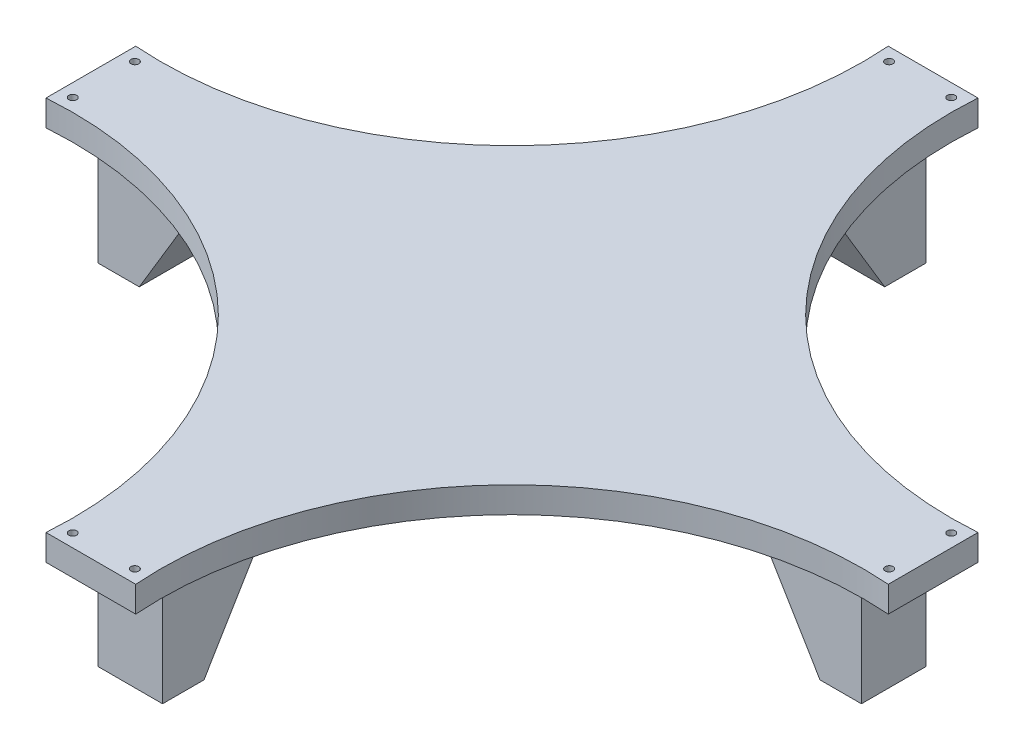
from build123d import *

# Parameters (mm, degrees)
SKETCH2_R           = 1.5
BOSS_EXTRUDE1_DEPTH = 10
SKETCH3_W           = 25
SKETCH3_H           = 40
SKETCH3_W_2         = 40
SKETCH3_H_2         = 25
BOSS_EXTRUDE2_DEPTH = 40
CUT_EXTRUDE1_DEPTH  = 40
CIRPATTERN1_COUNT   = 4


with BuildPart() as part:
    # Sketch2 → Boss-Extrude1 (new body)
    with BuildSketch(Plane(origin=(0, 0, 0), x_dir=(1, 0, 0), z_dir=(0, 1, 0))):
        with BuildLine():
            Line((162.66, -17.328961432), (162.66, 17.328961432))
            ThreePointArc((162.66, 17.328961432), (56.705609793, 56.705609793), (17.328961432, 162.66))
            Line((17.328961432, 162.66), (-17.328961432, 162.66))
            ThreePointArc((-17.328961432, 162.66), (-56.705609793, 56.705609793), (-162.66, 17.328961432))
            Line((-162.66, 17.328961432), (-162.66, -17.328961432))
            ThreePointArc((-162.66, -17.328961432), (-56.705609793, -56.705609793), (-17.328961432, -162.66))
            Line((-17.328961432, -162.66), (17.328961432, -162.66))
            ThreePointArc((17.328961432, -162.66), (56.705609793, -56.705609793), (162.66, -17.328961432))
        make_face()
        with Locations((-12, -157.66)):
            Circle(SKETCH2_R, mode=Mode.SUBTRACT)
        with Locations((-157.66, -12)):
            Circle(SKETCH2_R, mode=Mode.SUBTRACT)
        with Locations((12, -157.66)):
            Circle(SKETCH2_R, mode=Mode.SUBTRACT)
        with Locations((157.66, -12)):
            Circle(SKETCH2_R, mode=Mode.SUBTRACT)
        with Locations((-157.66, 12)):
            Circle(SKETCH2_R, mode=Mode.SUBTRACT)
        with Locations((-12, 157.66)):
            Circle(SKETCH2_R, mode=Mode.SUBTRACT)
        with Locations((157.66, 12)):
            Circle(SKETCH2_R, mode=Mode.SUBTRACT)
        with Locations((12, 157.66)):
            Circle(SKETCH2_R, mode=Mode.SUBTRACT)
    extrude(amount=BOSS_EXTRUDE1_DEPTH)

    # Sketch3 → Boss-Extrude2 (add)
    with BuildSketch(Plane.XZ):
        with Locations((0, 127.465698487)):
            Rectangle(SKETCH3_W, SKETCH3_H)
        with Locations((127.465698487, 0)):
            Rectangle(SKETCH3_W_2, SKETCH3_H_2)
        with Locations((0, -127.465698487)):
            Rectangle(SKETCH3_W, SKETCH3_H)
        with Locations((-127.465698487, 0)):
            Rectangle(SKETCH3_W_2, SKETCH3_H_2)
    extrude(amount=BOSS_EXTRUDE2_DEPTH)

    # Sketch4 → Cut-Extrude1 (cut)
    with BuildSketch(Plane(origin=(0, 0, -12.5), x_dir=(-1, 0, 0), z_dir=(0, 0, -1))):
        Polygon((-131.465698487, -40), (-107.465698487, 0), (-107.465698487, -40), align=None)
    cut_extrude1 = extrude(amount=-CUT_EXTRUDE1_DEPTH, mode=Mode.SUBTRACT)

    # CirPattern1: Cut-Extrude1 ×4 about axis
    cirpattern1_axis = Axis((0, 0, 0), (0, 1, 0))
    for i in range(1, CIRPATTERN1_COUNT):
        add(cut_extrude1.rotate(cirpattern1_axis, i * 360 / CIRPATTERN1_COUNT), mode=Mode.SUBTRACT)


solid = part.part
